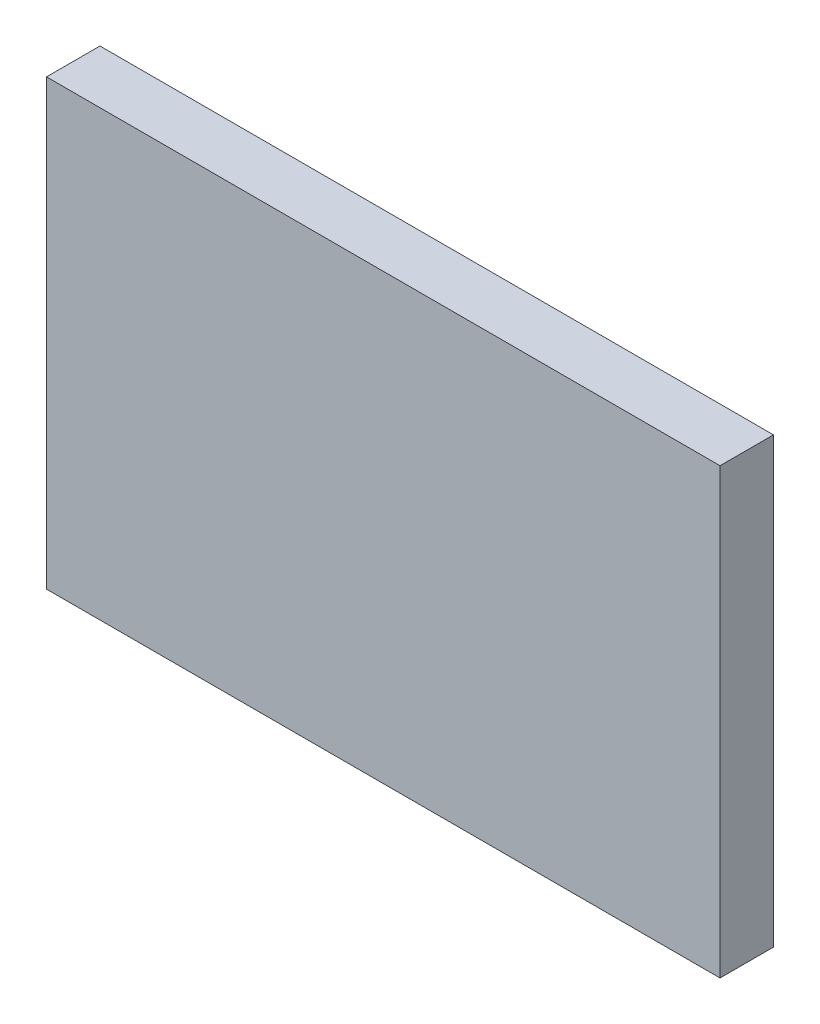
from build123d import *

# Parameters (mm, degrees)
SKETCH1_W      = 12.6
SKETCH1_H      = 8.3
EXTRUDE1_DEPTH = 1


with BuildPart() as part:
    # Sketch1 → Extrude1 (new body)
    with BuildSketch(Plane.XY):
        with Locations((6.3, -4.15)):
            Rectangle(SKETCH1_W, SKETCH1_H)
    extrude(amount=EXTRUDE1_DEPTH)


solid = part.part
